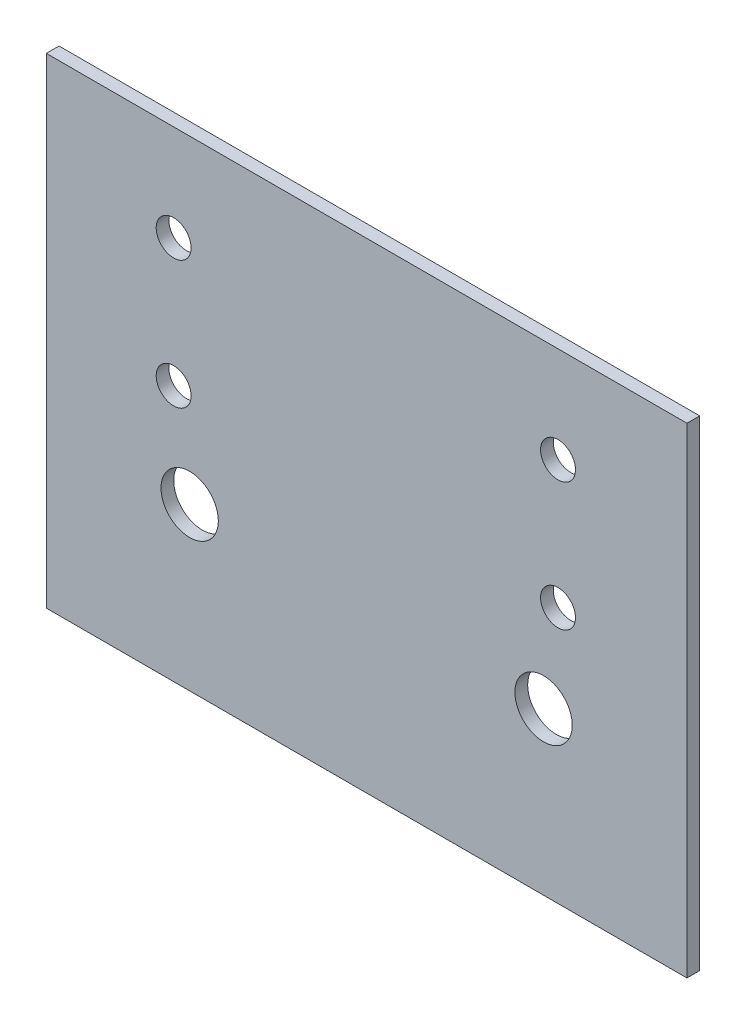
from build123d import *

# Parameters (mm, degrees)
SKETCH_1_W      = 402.234636872
SKETCH_1_H      = 301.675977654
SKETCH_1_R      = 10.960893855
SKETCH_1_R_2    = 18
EXTRUDE_1_DEPTH = 8


with BuildPart() as part:
    # 草图1 → 凸台-拉伸1 (new body)
    with BuildSketch(Plane.XY):
        with Locations((145.703353707, -116.444286207)):
            Rectangle(SKETCH_1_W, SKETCH_1_H)
        with Locations((24.534170175, -25.941492911)):
            Circle(SKETCH_1_R, mode=Mode.SUBTRACT)
        with Locations((265.874952297, -25.941492911)):
            Circle(SKETCH_1_R, mode=Mode.SUBTRACT)
        with Locations((24.534170175, -106.388420285)):
            Circle(SKETCH_1_R, mode=Mode.SUBTRACT)
        with Locations((265.874952297, -106.388420285)):
            Circle(SKETCH_1_R, mode=Mode.SUBTRACT)
        with Locations((34.590036096, -165.879725367)):
            Circle(SKETCH_1_R_2, mode=Mode.SUBTRACT)
        with Locations((256.816671318, -165.879725367)):
            Circle(SKETCH_1_R_2, mode=Mode.SUBTRACT)
    extrude(amount=EXTRUDE_1_DEPTH)


solid = part.part
